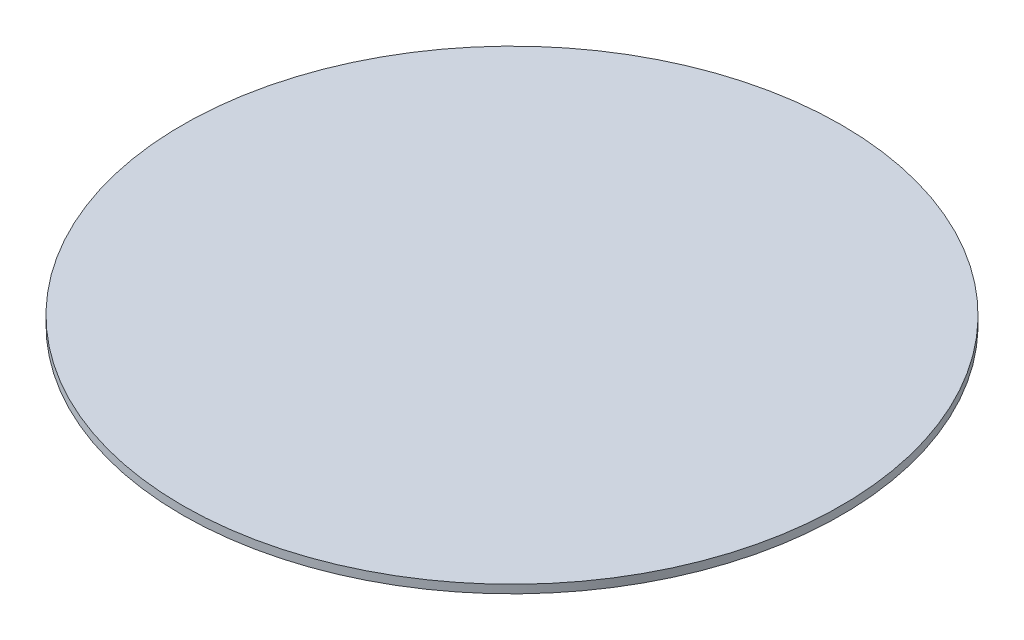
from build123d import *

# Parameters (mm, degrees)
SKETCH1_W = 119
SKETCH1_H = 3


with BuildPart() as part:
    # Sketch1 → Revolve1 (revolve)
    with BuildSketch(Plane.XY):
        with Locations((59.5, 1.5)):
            Rectangle(SKETCH1_W, SKETCH1_H)
    revolve(axis=Axis((0, 3, 0), (0, -1, 0)))


solid = part.part
